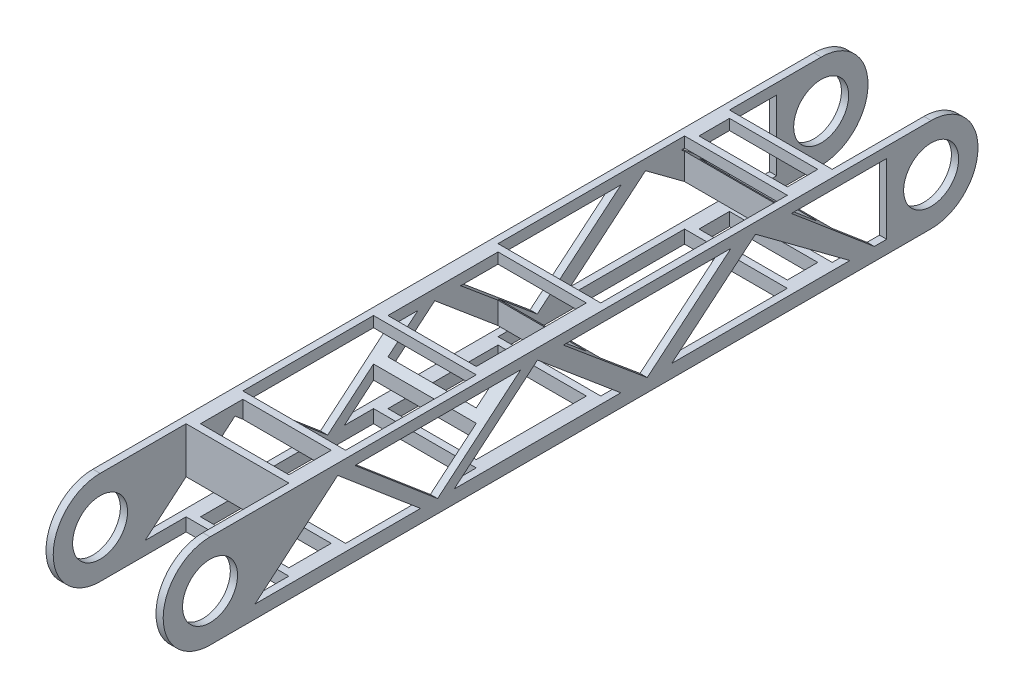
from build123d import *

# Parameters (mm, degrees)
CROQUIS1_R              = 15.25
SALIENTE_EXTRUIR1_DEPTH = 70
CROQUIS2_W              = 57
CROQUIS2_H              = 84.437125565
CROQUIS2_H_2            = 89.497342593
CROQUIS2_H_3            = 103.4811418
CROQUIS2_H_4            = 72.483550253
CORTAR_EXTRUIR1_DEPTH   = 70
CORTAR_EXTRUIR2_DEPTH   = 70
CROQUIS4_R              = 15.25
CORTAR_EXTRUIR3_DEPTH   = 2.5
CROQUIS5_R              = 15.25
CORTAR_EXTRUIR4_DEPTH   = 2.5
CROQUIS6_W              = 49
CROQUIS6_H              = 61.062323931
CORTAR_EXTRUIR5_DEPTH   = 70
CROQUIS7_W              = 49
CROQUIS7_H              = 23.488755438
CORTAR_EXTRUIR6_DEPTH   = 70
CROQUIS8_W              = 49
CROQUIS8_H              = 16.905630738
CORTAR_EXTRUIR7_DEPTH   = 70
CORTAR_EXTRUIR8_DEPTH   = 75


with BuildPart() as part:
    # Croquis1 → Saliente-Extruir1 (new body)
    with BuildSketch(Plane(origin=(0, 0, 0), x_dir=(0, 0, -1), z_dir=(1, 0, 0))):
        with BuildLine():
            Line((-200, 35), (200, 35))
            ThreePointArc((200, 35), (235, 0), (200, -35))
            Line((200, -35), (-200, -35))
            ThreePointArc((-200, -35), (-235, 0), (-200, 35))
        make_face()
        with Locations((-200, 0)):
            Circle(CROQUIS1_R, mode=Mode.SUBTRACT)
        with Locations((200, 0)):
            Circle(CROQUIS1_R, mode=Mode.SUBTRACT)
    extrude(amount=SALIENTE_EXTRUIR1_DEPTH)

    # Croquis2 → Cortar-Extruir1 (cut)
    with BuildSketch(Plane(origin=(0, 35, 0), x_dir=(1, 0, 0), z_dir=(0, 1, 0))):
        with Locations((35, -194.508891983)):
            Rectangle(CROQUIS2_W, CROQUIS2_H)
        with Locations((35, 193.879744257)):
            Rectangle(CROQUIS2_W, CROQUIS2_H_2)
        with Locations((35, 72.484871322)):
            Rectangle(CROQUIS2_W, CROQUIS2_H_3)
        with Locations((35, -84.559798636)):
            Rectangle(CROQUIS2_W, CROQUIS2_H_4)
    extrude(amount=-CORTAR_EXTRUIR1_DEPTH, mode=Mode.SUBTRACT)

    # Croquis3 → Cortar-Extruir2 (cut)
    with BuildSketch(Plane(origin=(70, 0, 0), x_dir=(0, 0, -1), z_dir=(1, 0, 0))):
        with BuildLine():
            Line((-200, -35), (200, -35))
            ThreePointArc((200, -35), (235, 0), (200, 35))
            Line((200, 35), (-200, 35))
            ThreePointArc((-200, 35), (-235, 0), (-200, -35))
        make_face()
        with BuildLine():
            ThreePointArc((-200, 26), (-226, 0), (-200, -26))
            Line((-200, -26), (200, -26))
            ThreePointArc((200, -26), (226, 0), (200, 26))
            Line((200, 26), (-200, 26))
        make_face(mode=Mode.SUBTRACT)
    extrude(amount=-CORTAR_EXTRUIR2_DEPTH, mode=Mode.SUBTRACT)

    # Croquis4 → Cortar-Extruir3 (cut)
    with BuildSketch(Plane(origin=(70, 0, 0), x_dir=(0, 0, -1), z_dir=(1, 0, 0))):
        with BuildLine():
            Line((-200, 26), (200, 26))
            ThreePointArc((200, 26), (226, 0), (200, -26))
            Line((200, -26), (-200, -26))
            ThreePointArc((-200, -26), (-226, 0), (-200, 26))
        make_face()
        with Locations((-200, 0)):
            Circle(CROQUIS4_R, mode=Mode.SUBTRACT)
    extrude(amount=-CORTAR_EXTRUIR3_DEPTH, mode=Mode.SUBTRACT)

    # Croquis5 → Cortar-Extruir4 (cut)
    with BuildSketch(Plane.ZY):
        with BuildLine():
            Line((-200, 26), (200, 26))
            ThreePointArc((200, 26), (226, 0), (200, -26))
            Line((200, -26), (-200, -26))
            ThreePointArc((-200, -26), (-226, 0), (-200, 26))
        make_face()
        with Locations((200, 0)):
            Circle(CROQUIS5_R, mode=Mode.SUBTRACT)
        with Locations((-200, 0)):
            Circle(CROQUIS5_R, mode=Mode.SUBTRACT)
    extrude(amount=-CORTAR_EXTRUIR4_DEPTH, mode=Mode.SUBTRACT)

    # Croquis6 → Cortar-Extruir5 (cut)
    with BuildSketch(Plane(origin=(0, 26, 0), x_dir=(1, 0, 0), z_dir=(0, 1, 0))):
        with Locations((35, -13.786861543)):
            Rectangle(CROQUIS6_W, CROQUIS6_H)
    extrude(amount=-CORTAR_EXTRUIR5_DEPTH, mode=Mode.SUBTRACT)

    # Croquis7 → Cortar-Extruir6 (cut)
    with BuildSketch(Plane(origin=(0, 26, 0), x_dir=(1, 0, 0), z_dir=(0, 1, 0))):
        with Locations((35, -136.545951481)):
            Rectangle(CROQUIS7_W, CROQUIS7_H)
    extrude(amount=-CORTAR_EXTRUIR6_DEPTH, mode=Mode.SUBTRACT)

    # Croquis8 → Cortar-Extruir7 (cut)
    with BuildSketch(Plane(origin=(0, 26, 0), x_dir=(1, 0, 0), z_dir=(0, 1, 0))):
        with Locations((35, 136.678257591)):
            Rectangle(CROQUIS8_W, CROQUIS8_H)
    extrude(amount=-CORTAR_EXTRUIR7_DEPTH, mode=Mode.SUBTRACT)

    # Croquis9 → Cortar-Extruir8 (cut, symmetric)
    with BuildSketch(Plane(origin=(0, 0, 0), x_dir=(0, 0, -1), z_dir=(1, 0, 0))):
        Polygon((-175.016247614, -18.719139012), (-129.175761304, 20.119342374), (-83.252481771, -18.719139012), align=None)
        Polygon((-64.5759486, -18.719139012), (27.853775471, -18.719139012), (-18.361086565, 20.119342374), align=None)
        Polygon((-3.953316698, 20.119342374), (88.969737905, 20.119342374), (42.508210603, -18.719139012), align=None)
        Polygon((175.339862658, 20.119342374), (175.339862658, -18.719139012), (168.473319463, -18.719139012), (122.506063728, 20.119342374), align=None)
        Polygon((-119.659693674, 20.119342374), (-73.771877896, -18.719139012), (-27.662190874, 20.119342374), align=None)
        Polygon((56.100678697, -18.719139012), (102.562205998, 20.119342374), (154.954992104, -18.719139012), align=None)
    extrude(amount=CORTAR_EXTRUIR8_DEPTH, both=True, mode=Mode.SUBTRACT)


solid = part.part
